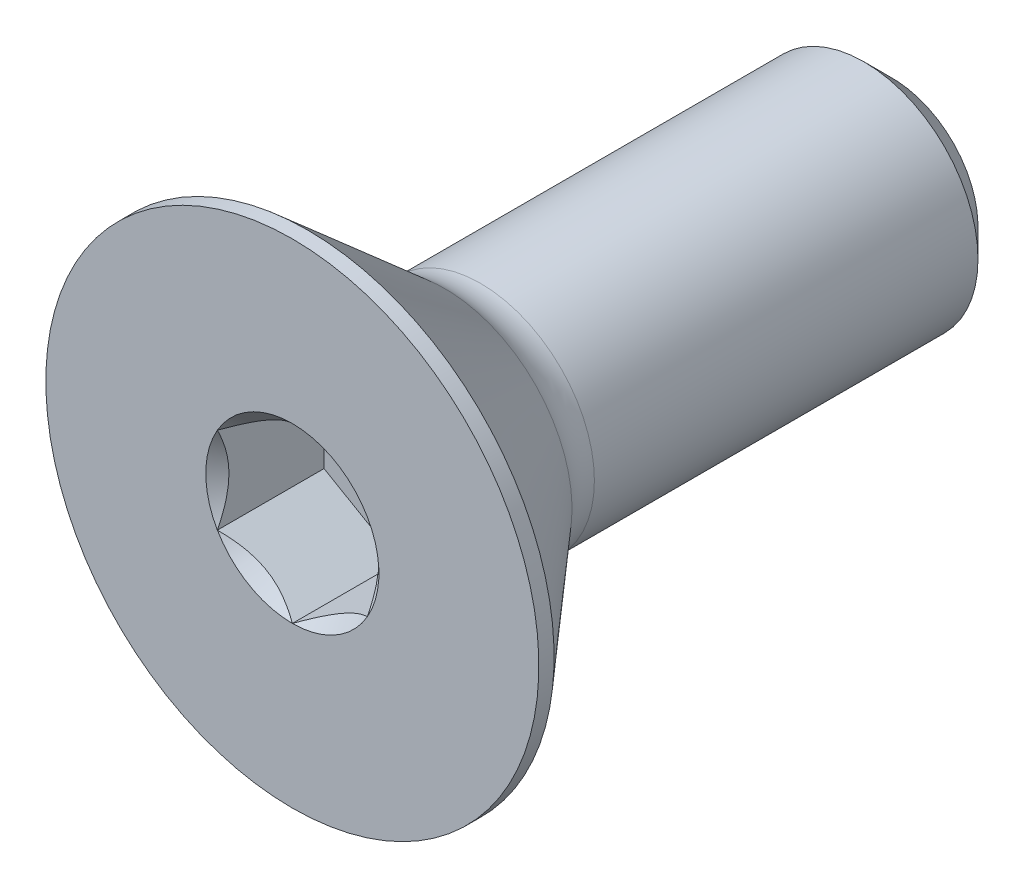
from build123d import *

# Parameters (mm, degrees)
SKETCH1_W          = 12.7
SKETCH1_H          = 2.413
CHAMFER1_SIZE      = 0.5953125
CUT_EXTRUDE2_DEPTH = 2.25806


with BuildPart() as part:
    # Sketch1 → Revolve1 (revolve)
    with BuildSketch(Plane(origin=(0, 0, 0), x_dir=(0, 0, -1), z_dir=(1, 0, 0))):
        with Locations((6.35, 1.2065)):
            Rectangle(SKETCH1_W, SKETCH1_H)
    revolve(axis=Axis((0, 0, -12.7), (0, 0, 1)))

    # Chamfer1
    chamfer1_edges = [part.edges().sort_by_distance(p)[0] for p in [
        (0, -2.413, -12.7),
    ]]
    chamfer(chamfer1_edges, length=CHAMFER1_SIZE)


with BuildPart() as body_2:
    # Sketch7 → Revolve2 (revolve)
    with BuildSketch(Plane(origin=(0, 0, 0), x_dir=(0, 0, -1), z_dir=(1, 0, 0)), mode=Mode.PRIVATE) as revolve2_sk:
        with BuildLine():
            Line((0, 5.2197), (0.32258, 5.2197))
            Line((0.32258, 5.2197), (3.2258, 2.695969357))
            ThreePointArc((3.2258, 2.695969357), (3.578633365, 2.486055564), (3.982635924, 2.413))
            Line((3.982635924, 2.413), (3.982635924, 0))
            Line((3.982635924, 0), (0, 0))
            Line((0, 0), (0, 5.2197))
        make_face()
    revolve(revolve2_sk.sketch.rotate(Axis((0, 0, 0), (0, 0, -1)), 180), axis=Axis((0, 0, 0), (0, 0, -1)))

    # Boss-Extrude1 cone 1 section (through the dimple's axis) → Boss-Extrude1 (revolve)
    with BuildSketch(Plane(origin=(0, 0, -3.982635924), x_dir=(0, -1, 0), z_dir=(1, 0, 0))):
        Polygon((0, 0), (2.413, 0), (0, 2.413), align=None)
    revolve(axis=Axis((0, 0, -3.982635924), (0, 0, -1)))

    # Combine1: union part
    add(part.part)

    # Sketch5 → Cut-Extrude2 (cut)
    with BuildSketch(Plane.XY):
        Polygon((1.5875, -0.916543552), (1.5875, 0.916543552), (0, 1.833087105), (-1.5875, 0.916543552), (-1.5875, -0.916543552), (0, -1.833087105), align=None)
    extrude(amount=-CUT_EXTRUDE2_DEPTH, mode=Mode.SUBTRACT)

    # Cut-Extrude3 cone 1 section (through the dimple's axis) → Cut-Extrude3 (revolve, cut)
    with BuildSketch(Plane(origin=(0, 0, 0), x_dir=(0, -1, 0), z_dir=(1, 0, 0))):
        Polygon((0, 0), (1.833087105, 0), (0, 1.833087105), align=None)
    revolve(axis=Axis((0, 0, 0), (0, 0, -1)), mode=Mode.SUBTRACT)


solid = body_2.part
